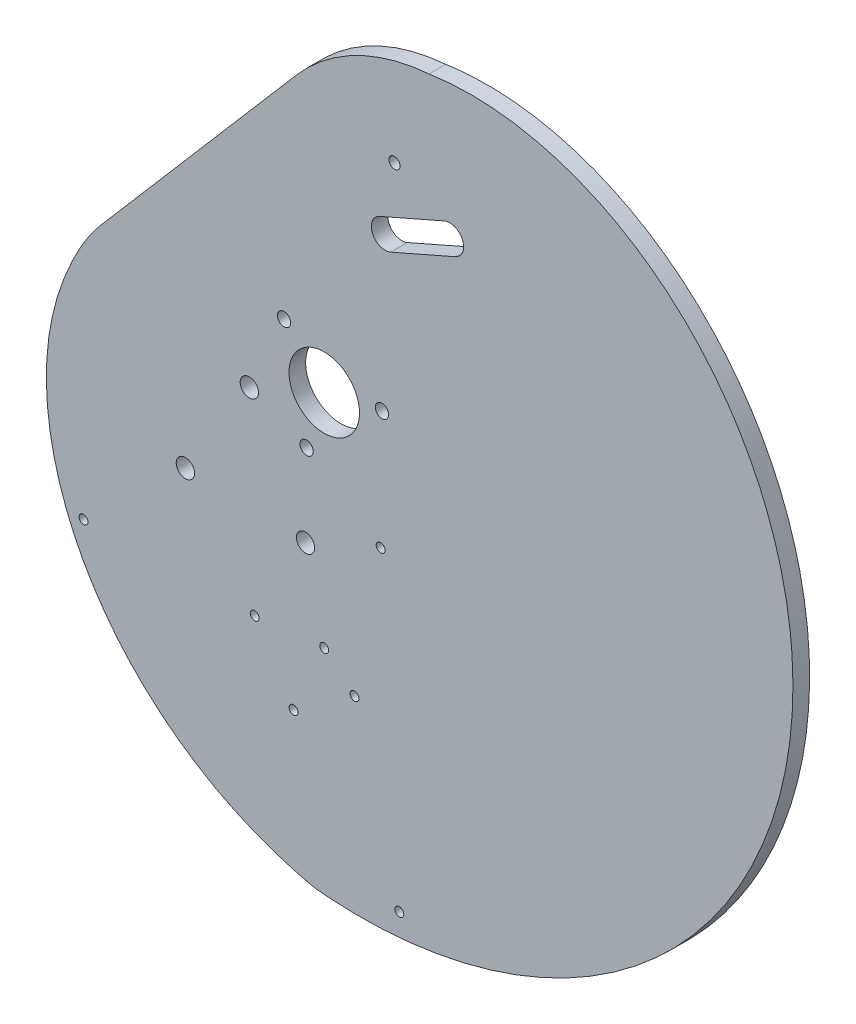
from build123d import *

# Parameters (mm, degrees)
SKETCH1_R                   = 6.35
BOSS_EXTRUDE1_DEPTH         = 1.5
CUT_EXTRUDE1_DEPTH          = 102.169930751
CUT_EXTRUDE1_DEPTH_BACK     = 102.169930751
FILLET1_R                   = 20
BOSS_EXTRUDE2_DEPTH         = 1.5
SKETCH7_R                   = 6.35
SKETCH7_R_2                 = 3.175
BOSS_EXTRUDE3_DEPTH         = 1.5
SKETCH8_R                   = 1
SKETCH8_R_2                 = 6.35
CUT_EXTRUDE2_DEPTH          = 116.300180911
CUT_EXTRUDE2_DEPTH_BACK     = 116.300180911
M4X0_7_TAPPED_HOLE1_D       = 3.3
M2_CLEARANCE_HOLE1_D        = 2.4
TAP_DRILL_FOR_M2X0_4_TAP1_D = 1.6
TAP_DRILL_FOR_M2X0_4_TAP2_D = 1.6


with BuildPart() as part:
    # Sketch1 → Boss-Extrude1 (new, symmetric)
    with BuildSketch(Plane.XY):
        with BuildLine():
            ThreePointArc((11.984914181, 27.895733584), (8.691133377, 29.180649151), (9.976048944, 32.474429955))
            Line((9.976048944, 32.474429955), (12.234616167, 33.46535768))
            ThreePointArc((12.234616167, 33.46535768), (8.26006825, 34.969173712), (5.615201844, 38.295308932))
            Line((5.615201844, 38.295308932), (3.856119442, 42.419673356))
            add(Edge.make_bspline(
                [(3.856119442, 42.419673356), (3.804269194, 42.380475154), (3.486745937, 42.138972836), (2.912619563, 41.685826384), (2.149082762, 41.044776761), (1.408732666, 40.385653153), (0.69201842, 39.710962437), (-0.000702823, 39.023274092), (-0.669224606, 38.325164066), (-1.313490613, 37.619209289), (-1.933594741, 36.907981167), (-2.529780734, 36.194039342), (-3.102441662, 35.479925366), (-3.652119172, 34.768156406), (-4.179502537, 34.061218936), (-4.68542751, 33.361562432), (-5.170874981, 32.671593072), (-5.636969475, 31.993667421), (-6.084977486, 31.330086125), (-6.5163057, 30.68308757), (-6.932499191, 30.054841594), (-7.335239472, 29.447442991), (-7.726343211, 28.862905788), (-8.107759261, 28.30315506), (-8.481572996, 27.770028153), (-8.850055929, 27.265150233), (-9.21599154, 26.789707359), (-9.58007402, 26.342396401), (-9.943199031, 25.921274986), (-10.306211946, 25.524302901), (-10.669815304, 25.149428396), (-11.03457423, 24.794597749), (-11.400917427, 24.457759077), (-11.769139802, 24.136868148), (-12.139404915, 23.829894257), (-12.511747444, 23.534826559), (-12.886075425, 23.249680558), (-13.262172288, 22.972504592), (-13.639698706, 22.701386132), (-14.018194373, 22.4344578), (-14.397079826, 22.169903041), (-14.775658393, 21.905961469), (-15.153118349, 21.640933911), (-15.528535328, 21.37318718), (-15.900874865, 21.101158728), (-16.268995598, 20.823360748), (-16.631651048, 20.538385549), (-16.987497448, 20.244905703), (-17.335071725, 19.941700072), (-17.674482118, 19.629485326), (-18.005889299, 19.308945872), (-18.329486913, 18.98074786), (-18.645506177, 18.6455329), (-18.954213469, 18.303917657), (-19.255909475, 17.956492143), (-19.550927855, 17.603818409), (-19.839633983, 17.246429189), (-20.122423608, 16.884826615), (-20.39972148, 16.519480973), (-20.671979932, 16.15082951), (-20.93967742, 15.77927529), (-21.203317027, 15.405186109), (-21.463424922, 15.028893458), (-21.720548787, 14.650691546), (-21.975256201, 14.270836377), (-22.228133, 13.889544888), (-22.479781587, 13.506994147), (-22.730819224, 13.123320602), (-22.981876279, 12.738619403), (-23.233594452, 12.35294377), (-23.486624965, 11.966304432), (-23.741626724, 11.578669117), (-23.999264462, 11.189962103), (-24.260206854, 10.800063825), (-24.52512461, 10.408810538), (-24.794688561, 10.015994037), (-25.069567717, 9.621361426), (-25.350427363, 9.224614974), (-25.637926993, 8.8254119), (-25.932718851, 8.423364715), (-26.235444149, 8.018039723), (-26.546738212, 7.608962846), (-26.867193334, 7.195608336), (-27.197393741, 6.777566684), (-27.537037782, 6.353934602), (-27.885559202, 5.923803469), (-28.242374703, 5.486366009), (-28.606855737, 5.040842301), (-28.978345064, 4.586492757), (-29.356154138, 4.122615768), (-29.739565815, 3.648549546), (-30.127835637, 3.163672741), (-30.520193566, 2.667405334), (-30.915845631, 2.159209384), (-31.313975642, 1.638589743), (-31.713746908, 1.10509472), (-32.114303997, 0.558316687), (-32.514774496, -0.002107372), (-32.914270801, -0.576495363), (-33.311891916, -1.165119646), (-33.70672526, -1.768206653), (-34.097848491, -2.385936568), (-34.484331334, -3.01844306), (-34.865237414, -3.665813085), (-35.239626095, -4.328086735), (-35.606554319, -5.00525716), (-35.965078448, -5.697270543), (-36.314256102, -6.404026134), (-36.653147994, -7.125376348), (-36.98081976, -7.861126926), (-37.296343783, -8.611037148), (-37.598801011, -9.374820113), (-37.887282738, -10.15214308), (-38.160892488, -10.942627847), (-38.418747446, -11.745851279), (-38.659981522, -12.561345551), (-38.883742182, -13.388599746), (-39.089211497, -14.227059816), (-39.27554787, -15.076191303), (-39.442240692, -15.935443066), (-39.58900499, -16.804297383), (-39.715531283, -17.682274795), (-39.821534024, -18.56888584), (-39.906736403, -19.463633732), (-39.970874682, -20.366013757), (-40.01369729, -21.27551381), (-40.034965324, -22.191614638), (-40.034452659, -23.113790166), (-40.011946156, -24.041507803), (-39.967245835, -24.974228766), (-39.900165044, -25.911408403), (-39.810530622, -26.852496518), (-39.698183052, -27.796937709), (-39.56297661, -28.744171699), (-39.4047795, -29.693633681), (-39.223473982, -30.64475466), (-39.018956498, -31.596961802), (-38.791137779, -32.549678783), (-38.539942955, -33.502326148), (-38.265311644, -34.454321664), (-37.967198044, -35.405080681), (-37.645571006, -36.354016496), (-37.300414107, -37.300540716), (-36.931725709, -38.244063627), (-36.539519007, -39.18399456), (-36.123822074, -40.119742265), (-35.684677893, -41.050715279), (-35.222144381, -41.976322302), (-34.736294403, -42.89597257), (-34.227215775, -43.809076229), (-33.695011264, -44.715044715), (-33.139798572, -45.613291121), (-32.561710315, -46.503230581), (-31.960893988, -47.384280643), (-31.337511928, -48.255861642), (-30.69174126, -49.117397078), (-30.023773839, -49.96831399), (-29.333816181, -50.808043326), (-28.622089382, -51.636020317), (-27.888829033, -52.451684847), (-27.134285123, -53.25448182), (-26.358721931, -54.04386153), (-25.562417912, -54.819280022), (-24.745665571, -55.580199454), (-23.908771332, -56.326088459), (-23.052055394, -57.0564225), (-22.175851579, -57.770684224), (-21.280507172, -58.468363812), (-20.366382752, -59.148959324), (-19.433852012, -59.811977048), (-18.483301577, -60.456931829), (-17.515130802, -61.083347415), (-16.529751575, -61.690756781), (-15.527588097, -62.278702456), (-14.50907667, -62.846736843), (-13.474665463, -63.39442255), (-12.424814268, -63.921332635), (-11.359994294, -64.427051169), (-10.280687768, -64.911172569), (-9.187388219, -65.373305515), (-8.080598179, -65.813059652), (-6.960836498, -66.230096831), (-5.828609627, -66.623940268), (-4.684517934, -66.994691537), (-3.528855652, -67.340343195), (-2.3631095, -67.666856553), (-1.184338477, -67.950378607), (-0.400093515, -68.169065005), (0, -68.230921715)],
                knots=[0.595074645, 0.595074645, 0.595074645, 0.595074645, 0.59561552, 0.598394199, 0.601160164, 0.603910525, 0.606641733, 0.609350191, 0.612032273, 0.614684334, 0.617302722, 0.619883791, 0.622423916, 0.624919509, 0.627367038, 0.629763043, 0.632104166, 0.634387177, 0.636609005, 0.638766786, 0.640857908, 0.642880081, 0.644831406, 0.646710483, 0.648516525, 0.650249514, 0.65191136, 0.653508519, 0.655048349, 0.65653798, 0.657984241, 0.659393583, 0.66077201, 0.662125022, 0.663457568, 0.664774018, 0.666078151, 0.667373165, 0.668661696, 0.669945853, 0.671227263, 0.672507127, 0.673786273, 0.67506522, 0.676344239, 0.677623416, 0.678902717, 0.68018205, 0.681461324, 0.682740438, 0.684019262, 0.685297659, 0.686575488, 0.687852615, 0.689128915, 0.690404281, 0.691678632, 0.692951916, 0.694224122, 0.695495279, 0.696765474, 0.698034846, 0.699303605, 0.70057203, 0.70184048, 0.703109399, 0.704379325, 0.705650892, 0.706924838, 0.708202013, 0.709483377, 0.710770009, 0.712063109, 0.713363997, 0.714674119, 0.715995039, 0.717328447, 0.718676146, 0.720040056, 0.721422204, 0.722824718, 0.724249822, 0.725699824, 0.727177002, 0.72868281, 0.730218172, 0.731783831, 0.733380363, 0.735008197, 0.736667628, 0.738358831, 0.740081872, 0.741836722, 0.743623264, 0.745441305, 0.747290584, 0.749170776, 0.751081502, 0.753022336, 0.754992805, 0.756992401, 0.759020578, 0.761076761, 0.763160347, 0.76527071, 0.767407202, 0.769569155, 0.771755887, 0.7739667, 0.776200882, 0.778457713, 0.780736462, 0.783036392, 0.785356757, 0.787696808, 0.790055792, 0.792432952, 0.794827532, 0.797238799, 0.799666426, 0.802110394, 0.804570687, 0.807047284, 0.809540165, 0.812049305, 0.814574675, 0.817116246, 0.819673984, 0.822247852, 0.824837811, 0.82744382, 0.830065834, 0.832703806, 0.835357687, 0.838027424, 0.840712962, 0.843414244, 0.84613121, 0.848863798, 0.851611942, 0.854375576, 0.857154631, 0.859949033, 0.862758708, 0.865583582, 0.868423573, 0.871278601, 0.874148584, 0.877033434, 0.879933066, 0.882847387, 0.885776307, 0.888719732, 0.891677564, 0.894649707, 0.897636058, 0.900636516, 0.903650977, 0.906679333, 0.909721476, 0.912777297, 0.915846682, 0.918929518, 0.922025687, 0.925135072, 0.928257554, 0.931393009, 0.934541315, 0.937702347, 0.940875975, 0.944062073, 0.947260508, 0.950471149, 0.95369386, 0.956928506, 0.960174949, 0.96343305, 0.966702667, 0.969983657, 0.973275876, 0.976579178, 0.979893415, 0.983218438, 0.986554095, 0.989900235, 0.993256703, 0.996623344, 1, 1, 1, 1], degree=3))
            add(Edge.make_bspline(
                [(0, -68.230921715), (0.393333706, -68.291733321), (1.194961176, -68.321276753), (2.388868431, -68.414811628), (3.58891617, -68.470136134), (4.791044831, -68.510535556), (5.995946289, -68.52954927), (7.203026535, -68.528713614), (8.412027616, -68.507423129), (9.62259203, -68.465654591), (10.83437986, -68.403235569), (12.047037443, -68.320041284), (13.260205927, -68.215942066), (14.473519127, -68.090817818), (15.686604264, -67.944554476), (16.899081946, -67.777045295), (18.110566359, -67.588190842), (19.320665416, -67.377899329), (20.528980925, -67.146086849), (21.73510877, -66.892677633), (22.938639087, -66.6176043), (24.139156466, -66.320808097), (25.336240146, -66.002239142), (26.529464226, -65.661856654), (27.718397887, -65.299629187), (28.90260561, -64.915534847), (30.081647414, -64.509561514), (31.255079097, -64.081707052), (32.42245248, -63.631979515), (33.58331567, -63.160397343), (34.737213315, -62.666989561), (35.883686879, -62.151795956), (37.022274916, -61.614867262), (38.152513354, -61.056265327), (39.273935784, -60.476063279), (40.386073758, -59.87434568), (41.488457085, -59.251208675), (42.580614147, -58.606760131), (43.662072205, -57.941119771), (44.732357722, -57.254419292), (45.790996682, -56.546802486), (46.837514925, -55.81842534), (47.871438475, -55.069456136), (48.89229388, -54.300075538), (49.899608554, -53.51047667), (50.892911122, -52.700865183), (51.871731772, -51.87145932), (52.835602603, -51.022489959), (53.784057989, -50.154200657), (54.71663493, -49.26684768), (55.632873421, -48.360700021), (56.532316811, -47.436039411), (57.414512174, -46.493160317), (58.279010671, -45.532369935), (59.125367928, -44.553988165), (59.953144401, -43.558347582), (60.761905749, -42.545793391), (61.55122321, -41.516683378), (62.320673971, -40.471387842), (63.069841543, -39.410289525), (63.798316132, -38.333783527), (64.505695017, -37.242277204), (65.191582915, -36.13619007), (65.85559236, -35.015953676), (66.497344063, -33.882011479), (67.11646729, -32.734818707), (67.71260022, -31.574842209), (68.285390316, -30.402560293), (68.834494677, -29.218462553), (69.359580408, -28.023049692), (69.860324965, -26.816833323), (70.336416512, -25.60033577), (70.787554269, -24.374089852), (71.213448854, -23.13863866), (71.613822626, -21.894535318), (71.988410015, -20.642342743), (72.336957858, -19.382633384), (72.659225719, -18.115988959), (72.954986211, -16.843000179), (73.224025309, -15.564266461), (73.466142659, -14.28039563), (73.681151874, -12.992003617), (73.868880836, -11.699714142), (74.029171977, -10.404158388), (74.161882563, -9.10597467), (74.266884966, -7.805808087), (74.344066927, -6.504310174), (74.393331816, -5.202138538), (74.414598879, -3.89995649), (74.407803478, -2.598432666), (74.372897323, -1.29824064), (74.309848696, -5.853e-05), (74.218642658, 1.295431404), (74.099281259, 2.587543173), (73.95178373, 3.875587471), (73.776186663, 5.158872107), (73.572544188, 6.43670243), (73.340928136, 7.708381771), (73.081428188, 8.973211889), (72.794152019, 10.230493418), (72.47922543, 11.479526328), (72.13679246, 12.719610386), (71.767015501, 13.950045625), (71.37007539, 15.170132817), (70.946171493, 16.379173951), (70.495521777, 17.576472716), (70.018362872, 18.761334989), (69.514950114, 19.933069325), (68.985557583, 21.090987453), (68.430478125, 22.234404772), (67.850023359, 23.362640855), (67.244523678, 24.47501995), (66.614328227, 25.570871489), (65.959804877, 26.649530597), (65.281340181, 27.710338599), (64.579339317, 28.752643533), (63.85422602, 29.775800665), (63.106442497, 30.779173), (62.33644933, 31.762131799), (61.544725366, 32.724057086), (60.731767601, 33.66433818), (59.898090995, 34.582374149), (59.044228508, 35.477574541), (58.170730235, 36.349359075), (57.278166357, 37.197160694), (56.367121668, 38.020410915), (55.438270074, 38.818621759), (54.492318121, 39.591335254), (53.529982536, 40.3381068), (52.551992493, 41.058512637), (51.559087829, 41.752148676), (50.552018856, 42.418631155), (49.531545735, 43.057596786), (48.498437965, 43.668703015), (47.453473832, 44.251628246), (46.397439863, 44.806072049), (45.331130274, 45.331755356), (44.255346411, 45.828420647), (43.17089619, 46.295832116), (42.078593533, 46.733775825), (40.979257798, 47.142059848), (39.873713209, 47.520514394), (38.762788284, 47.868991924), (37.647315256, 48.187367242), (36.528129497, 48.475537585), (35.406068937, 48.733422689), (34.281973488, 48.960964845), (33.156684455, 49.158128938), (32.031043959, 49.324902476), (30.905894352, 49.461295599), (29.78207764, 49.567341079), (28.66043489, 49.643094299), (27.541805663, 49.688633226), (26.427027423, 49.704058363), (25.316934962, 49.689492689), (24.212359828, 49.645081585), (23.114129743, 49.570992746), (22.023068037, 49.46741608), (20.939993076, 49.334563587), (19.865717696, 49.172669234), (19.050939925, 49.026743912), (18.594215776, 48.936446476), (18.491236259, 48.915651329)],
                knots=[0, 0, 0, 0, 0.003319606, 0.00664483, 0.00997572, 0.013312315, 0.016654652, 0.020002764, 0.023356679, 0.026716422, 0.030082012, 0.033453467, 0.036830797, 0.040214011, 0.043603114, 0.046998106, 0.050398984, 0.05380574, 0.057218364, 0.060636841, 0.064061153, 0.067491279, 0.070927192, 0.074368865, 0.077816264, 0.081269354, 0.084728096, 0.088192446, 0.09166236, 0.095137787, 0.098618675, 0.102104968, 0.105596607, 0.10909353, 0.112595671, 0.116102963, 0.119615332, 0.123132706, 0.126655005, 0.130182149, 0.133714056, 0.137250637, 0.140791804, 0.144337465, 0.147887524, 0.151441884, 0.155000443, 0.158563099, 0.162129745, 0.165700272, 0.169274569, 0.172852522, 0.176434014, 0.180018926, 0.183607137, 0.187198521, 0.190792953, 0.194390304, 0.197990441, 0.201593231, 0.205198539, 0.208806224, 0.212416148, 0.216028167, 0.219642135, 0.223257906, 0.226875331, 0.230494258, 0.234114533, 0.237736001, 0.241358506, 0.244981886, 0.248605983, 0.252230632, 0.255855669, 0.259480928, 0.263106241, 0.266731437, 0.270356345, 0.273980794, 0.277604607, 0.281227611, 0.284849627, 0.288470478, 0.292089983, 0.295707963, 0.299324234, 0.302938615, 0.306550921, 0.310160967, 0.313768569, 0.317373538, 0.320975689, 0.324574833, 0.328170782, 0.331763348, 0.335352341, 0.338937573, 0.342518853, 0.346095993, 0.349668803, 0.353237093, 0.356800674, 0.360359359, 0.363912958, 0.367461284, 0.37100415, 0.37454137, 0.37807276, 0.381598135, 0.385117313, 0.388630113, 0.392136355, 0.395635862, 0.399128458, 0.402613969, 0.406092224, 0.409563054, 0.413026294, 0.416481778, 0.419929348, 0.423368847, 0.426800121, 0.43022302, 0.4336374, 0.437043112, 0.440439966, 0.443827754, 0.447206268, 0.450575308, 0.453934675, 0.457284173, 0.460623612, 0.463952804, 0.467271567, 0.470579721, 0.473877092, 0.477163509, 0.480438807, 0.483702825, 0.486955407, 0.490196401, 0.493425661, 0.496643048, 0.499848424, 0.50304166, 0.506222633, 0.509391223, 0.512547319, 0.515690814, 0.518821608, 0.521939609, 0.52504473, 0.528136891, 0.531216019, 0.53428205, 0.537334925, 0.540374595, 0.543401017, 0.546414157, 0.549413988, 0.550288202, 0.550288202, 0.550288202, 0.550288202], degree=3))
            Line((18.491236259, 48.915651329), (20.341962163, 44.576418519))
            ThreePointArc((20.341962163, 44.576418519), (20.922430656, 40.447066292), (19.347370503, 36.586019931))
            Line((19.347370503, 36.586019931), (21.605937727, 37.576947657))
            ThreePointArc((21.605937727, 37.576947657), (24.899718531, 36.29203209), (23.614802964, 32.998251286))
            Line((23.614802964, 32.998251286), (11.984914181, 27.895733584))
        make_face()
        Circle(SKETCH1_R, mode=Mode.SUBTRACT)
    extrude(amount=BOSS_EXTRUDE1_DEPTH, both=True)

    # Sketch2 → Cut-Extrude1 (cut, two sides)
    with BuildSketch(Plane.XY) as cut_extrude1_sk:
        Polygon((-35.700141367, -3.650772794), (-7.072677907, 43.311946145), (4.622228263, 43.311946145), (7.657062795, 40.706225638), (-41.200196706, -16.19692185), align=None)
    extrude(amount=CUT_EXTRUDE1_DEPTH, mode=Mode.SUBTRACT)
    extrude(cut_extrude1_sk.sketch, amount=-CUT_EXTRUDE1_DEPTH_BACK, mode=Mode.SUBTRACT)

    # Fillet1
    fillet1_edges = [part.edges().sort_by_distance(p)[0] for p in [
        (-38.918855467, -13.539885857, -0.7499997),
    ]]
    fillet(fillet1_edges, radius=FILLET1_R)

    # Sketch6 → Boss-Extrude2 (add, symmetric)
    with BuildSketch(Plane.XY):
        with BuildLine():
            Line((-40.240877686, 5.985028621), (-5.010941183, 47.016684781))
            ThreePointArc((-5.010941183, 47.016684781), (5.728997706, 55.445724795), (18.87378975, 59.134822925))
            add(Edge.make_bspline(
                [(18.87378975, 59.134822925), (22.516816499, 59.686781934), (26.193665623, 59.826089241), (33.45068059, 59.346128102), (37.03127521, 58.727162925), (43.967380955, 56.811462619), (47.322941455, 55.514954983), (53.707777021, 52.33122275), (56.737127918, 50.44408812), (62.389510018, 46.169164114), (65.013399799, 43.779091446), (69.784563311, 38.606399125), (71.934248393, 35.823640098), (75.732728508, 29.964309697), (77.38163003, 26.887763022), (80.164369364, 20.532587656), (81.298305727, 17.253908281), (83.048505582, 10.579036383), (83.664794752, 7.182960151), (84.3865512, 0.351701111), (84.49206067, -3.083543307), (84.207163067, -9.921041673), (83.816786418, -13.323289058), (82.562035426, -20.02858371), (81.697681537, -23.331653399), (78.43581289, -33.001341548), (75.366981688, -39.125760708), (67.729460455, -50.317148913), (63.161306968, -55.384041979), (52.884055324, -64.145782257), (47.175773764, -67.840270189), (35.026492532, -73.650102546), (28.586660871, -75.765074216), (18.701604185, -77.686070484), (15.369124025, -78.118771701), (10.354347453, -78.456714462), (8.679694279, -78.517619619), (6.587494274, -78.529369489), (6.170144087, -78.528514895), (5.334254192, -78.520512469), (4.913726597, -78.513297138), (4.071953989, -78.491958341), (3.658588776, -78.478091881), (3.049726248, -78.454186132), (2.84322124, -78.445541202), (2.413523355, -78.425490471), (2.191852793, -78.414139452), (1.849187473, -78.394199653), (1.730797282, -78.386869887), (1.509810446, -78.372493071), (1.405806762, -78.365417657), (1.113185905, -78.345280212), (0.943966862, -78.333383035), (0.764379497, -78.321776976), (0.73005815, -78.319613099), (0.664594577, -78.315610277), (0.63534896, -78.313880378), (0.539106387, -78.308417555), (0.45074868, -78.303757443), (0.113509584, -78.284976779), (-0.207625858, -78.267133918), (-0.83334031, -78.206206545), (-1.065924997, -78.179928196), (-1.449875604, -78.125911632), (-1.586886359, -78.10482735), (-1.843429138, -78.061893669), (-1.9656288, -78.039781678), (-2.546485276, -77.928478506), (-2.914665113, -77.838372208), (-3.330367332, -77.733106974), (-3.446176837, -77.702738066), (-3.586243748, -77.666027804), (-3.627318292, -77.655250883), (-3.698237511, -77.636744195), (-3.727677684, -77.629118622), (-3.894219178, -77.586307455), (-4.209129691, -77.507522483), (-4.621197785, -77.404374047), (-4.966045453, -77.314890963), (-5.081761547, -77.284340829), (-5.307399032, -77.223863613), (-5.640671054, -77.133177129), (-5.958569588, -77.043301816), (-6.3690401, -76.92534283), (-6.569336345, -76.86688301), (-7.182238051, -76.685143344), (-7.599606088, -76.557325569), (-8.429873477, -76.293278955), (-8.841288901, -76.157777564), (-10.890638145, -75.460646132), (-12.514573758, -74.835436277), (-15.706026772, -73.455756722), (-17.275815259, -72.700597027), (-21.890382607, -70.242328218), (-24.840585086, -68.345949758), (-30.394739385, -64.064839156), (-32.998609007, -61.680083928), (-37.761620342, -56.464319213), (-39.920617277, -53.633310877), (-43.690890371, -47.586553566), (-45.302087265, -44.370646153), (-47.870223233, -37.640179849), (-48.827104768, -34.12524618), (-49.978597119, -26.91435666), (-50.172989153, -23.218002666), (-49.813728375, -17.658491884), (-49.585534592, -15.803221116), (-49.071422005, -13.036209995), (-48.870846793, -12.115044492), (-48.414877231, -10.293400604), (-48.159605564, -9.392104476), (-47.316449698, -6.721187383), (-46.650942966, -4.984635667), (-45.143678718, -1.623776037), (-44.301508679, 0.000832802), (-43.392795008, 1.558582512)],
                knots=[0, 0, 0, 0, 0.03125, 0.03125, 0.0625, 0.0625, 0.09375, 0.09375, 0.125, 0.125, 0.15625, 0.15625, 0.1875, 0.1875, 0.21875, 0.21875, 0.25, 0.25, 0.28125, 0.28125, 0.3125, 0.3125, 0.34375, 0.34375, 0.375, 0.375, 0.4375, 0.4375, 0.5, 0.5, 0.5625, 0.5625, 0.625, 0.625, 0.65625, 0.65625, 0.671875, 0.671875, 0.67578125, 0.67578125, 0.6796875, 0.6796875, 0.68359375, 0.68359375, 0.685546875, 0.685546875, 0.6875, 0.6875, 0.688476562, 0.688476562, 0.689453125, 0.689453125, 0.69140625, 0.69140625, 0.691894531, 0.691894531, 0.692382812, 0.692382812, 0.693359375, 0.693359375, 0.6953125, 0.6953125, 0.696289062, 0.696289062, 0.696777344, 0.696777344, 0.697265625, 0.697265625, 0.69921875, 0.69921875, 0.700195312, 0.700195312, 0.700683594, 0.700683594, 0.701171875, 0.701171875, 0.703125, 0.705078125, 0.705078125, 0.706054687, 0.706054687, 0.70703125, 0.708984375, 0.708984375, 0.7109375, 0.7109375, 0.71484375, 0.71484375, 0.71875, 0.71875, 0.734375, 0.734375, 0.75, 0.75, 0.78125, 0.78125, 0.8125, 0.8125, 0.84375, 0.84375, 0.875, 0.875, 0.90625, 0.90625, 0.9375, 0.9375, 0.953125, 0.953125, 0.9609375, 0.9609375, 0.96875, 0.96875, 0.984375, 0.984375, 1, 1, 1, 1], degree=3))
            ThreePointArc((-43.392795008, 1.558582512), (-41.917264231, 3.843316747), (-40.240877686, 5.985028621))
        make_face()
    extrude(amount=BOSS_EXTRUDE2_DEPTH, both=True)

    # Sketch7 → Boss-Extrude3 (add, symmetric)
    with BuildSketch(Plane.XY):
        Circle(SKETCH7_R)
        Circle(SKETCH7_R_2, mode=Mode.SUBTRACT)
    extrude(amount=BOSS_EXTRUDE3_DEPTH, both=True)

    # Sketch8 → Cut-Extrude2 (cut, two sides)
    with BuildSketch(Plane.XY) as cut_extrude2_sk:
        with Locations((12.655385599, 42.167672501)):
            Circle(SKETCH8_R)
        Circle(SKETCH8_R_2)
        with BuildLine():
            Line((9.976048944, 32.474429955), (21.605937727, 37.576947657))
            ThreePointArc((21.605937727, 37.576947657), (24.899718531, 36.29203209), (23.614802964, 32.998251286))
            Line((23.614802964, 32.998251286), (11.984914181, 27.895733584))
            ThreePointArc((11.984914181, 27.895733584), (8.691133377, 29.180649151), (9.976048944, 32.474429955))
        make_face()
    extrude(amount=CUT_EXTRUDE2_DEPTH, mode=Mode.SUBTRACT)
    extrude(cut_extrude2_sk.sketch, amount=-CUT_EXTRUDE2_DEPTH_BACK, mode=Mode.SUBTRACT)

    # M4x0.7 Tapped Hole1 (through all)
    with Locations(Plane.XY.offset(1.5)):
        with Locations((-13.488047982, -5.9360377), (-25.003814781, -24.270826649), (-3.367538379, -25.076378767)):
            Hole(M4X0_7_TAPPED_HOLE1_D / 2)

    # M2 Clearance Hole1 (through all)
    with Locations(Plane(origin=(0, 0, -1.5), x_dir=(-1, 0, 0), z_dir=(0, 0, -1))):
        with Locations((7.233951111, 7.840674418), (3.173247673, -10.185122641), (-10.407198784, 2.344448223)):
            Hole(M2_CLEARANCE_HOLE1_D / 2)

    # Tap Drill for M2x0.4 Tap1 (through all)
    with Locations(Plane(origin=(-43.353129439, -41.45965752, 1.5), x_dir=(1, 0, 0), z_dir=(0, 0, 1))):
        with Locations((0, 0), (56.879316866, -32.741237457), (37.830109929, -10.787750205), (48.798026946, -3.133849965), (53.514213435, 22.356147679)):
            Hole(TAP_DRILL_FOR_M2X0_4_TAP1_D / 2)

    # Tap Drill for M2x0.4 Tap2 (through all)
    with Locations(Plane(origin=(-12.52460351, -41.04915847, 10.62), x_dir=(1, 0, 0), z_dir=(0, 0, 1))):
        with Locations((0, 0), (12.52460351, 1.23011277)):
            Hole(TAP_DRILL_FOR_M2X0_4_TAP2_D / 2)


solid = part.part
